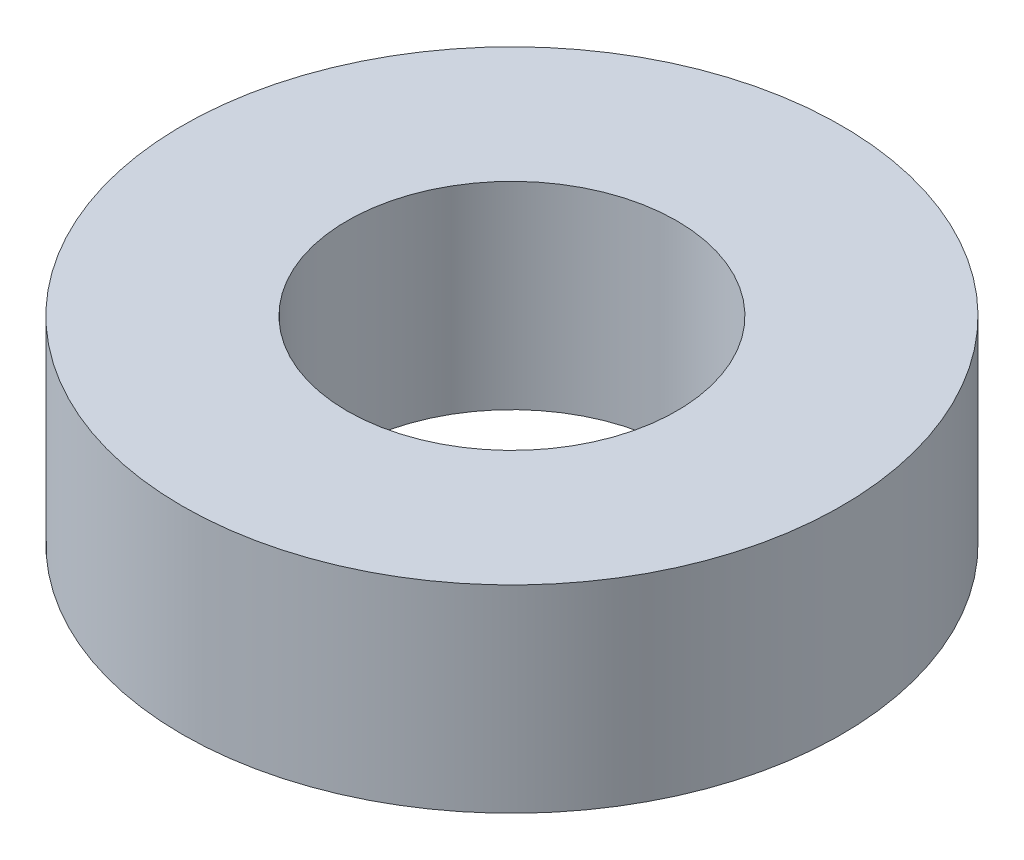
from build123d import *

# Parameters (mm, degrees)
SKETCH1_R           = 5
SKETCH1_R_2         = 2.5
BOSS_EXTRUDE1_DEPTH = 3


with BuildPart() as part:
    # Sketch1 → Boss-Extrude1 (new body)
    with BuildSketch(Plane(origin=(0, 0, 0), x_dir=(1, 0, 0), z_dir=(0, 1, 0))):
        Circle(SKETCH1_R)
        Circle(SKETCH1_R_2, mode=Mode.SUBTRACT)
    extrude(amount=BOSS_EXTRUDE1_DEPTH)


solid = part.part
